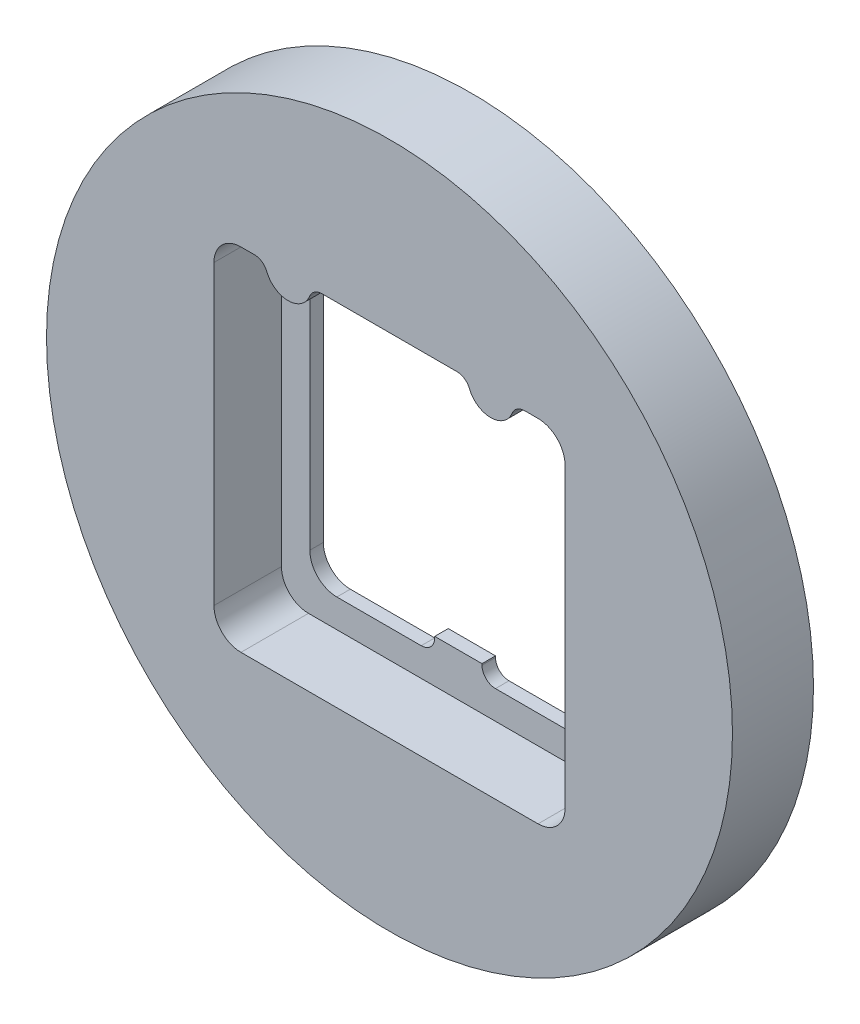
from build123d import *

# Parameters (mm, degrees)
SKETCH1_R           = 25.4
BOSS_EXTRUDE1_DEPTH = 6
CUT_EXTRUDE2_DEPTH  = 5
CUT_EXTRUDE3_DEPTH  = 2


with BuildPart() as part:
    # Sketch1 → Boss-Extrude1 (new body)
    with BuildSketch(Plane.XY):
        Circle(SKETCH1_R)
    extrude(amount=BOSS_EXTRUDE1_DEPTH)

    # Sketch2 → Cut-Extrude2 (cut)
    with BuildSketch(Plane.XY.offset(6)):
        with BuildLine():
            Line((-11, -13), (11, -13))
            ThreePointArc((11, -13), (12.414213562, -12.414213562), (13, -11))
            Line((13, -11), (13, 11))
            ThreePointArc((13, 11), (12.414213562, 12.414213562), (11, 13))
            Line((11, 13), (10.007987241, 13))
            ThreePointArc((10.007987241, 13), (9.446903633, 12.827759135), (9.079103078, 12.37037037))
            ThreePointArc((9.079103078, 12.37037037), (7.5, 11.3), (5.920896922, 12.37037037))
            ThreePointArc((5.920896922, 12.37037037), (5.553096367, 12.827759135), (4.992012759, 13))
            Line((4.992012759, 13), (-4.992012759, 13))
            ThreePointArc((-4.992012759, 13), (-5.553096367, 12.827759135), (-5.920896922, 12.37037037))
            ThreePointArc((-5.920896922, 12.37037037), (-7.5, 11.3), (-9.079103078, 12.37037037))
            ThreePointArc((-9.079103078, 12.37037037), (-9.446903633, 12.827759135), (-10.007987241, 13))
            Line((-10.007987241, 13), (-11, 13))
            ThreePointArc((-11, 13), (-12.414213562, 12.414213562), (-13, 11))
            Line((-13, 11), (-13, -11))
            ThreePointArc((-13, -11), (-12.414213562, -12.414213562), (-11, -13))
        make_face()
    extrude(amount=-CUT_EXTRUDE2_DEPTH, mode=Mode.SUBTRACT)

    # Sketch3 → Cut-Extrude3 (cut, through all)
    with BuildSketch(Plane.XY.offset(1)):
        with BuildLine():
            Line((-10.9, -8.9), (-10.9, 9.1))
            ThreePointArc((-10.9, 9.1), (-10.314213562, 10.514213562), (-8.9, 11.1))
            Line((-8.9, 11.1), (9.1, 11.1))
            ThreePointArc((9.1, 11.1), (10.514213562, 10.514213562), (11.1, 9.1))
            Line((11.1, 9.1), (11.1, -8.9))
            ThreePointArc((11.1, -8.9), (10.514213562, -10.314213562), (9.1, -10.9))
            Line((9.1, -10.9), (2.85, -10.9))
            ThreePointArc((2.85, -10.9), (2.142893219, -10.607106781), (1.85, -9.9))
            Line((1.85, -9.9), (1.85, -9.8))
            Line((1.85, -9.8), (-1.65, -9.8))
            Line((-1.65, -9.8), (-1.65, -9.9))
            ThreePointArc((-1.65, -9.9), (-1.942893219, -10.607106781), (-2.65, -10.9))
            Line((-2.65, -10.9), (-8.9, -10.9))
            ThreePointArc((-8.9, -10.9), (-10.314213562, -10.314213562), (-10.9, -8.9))
        make_face()
    extrude(amount=-CUT_EXTRUDE3_DEPTH, mode=Mode.SUBTRACT)


solid = part.part
